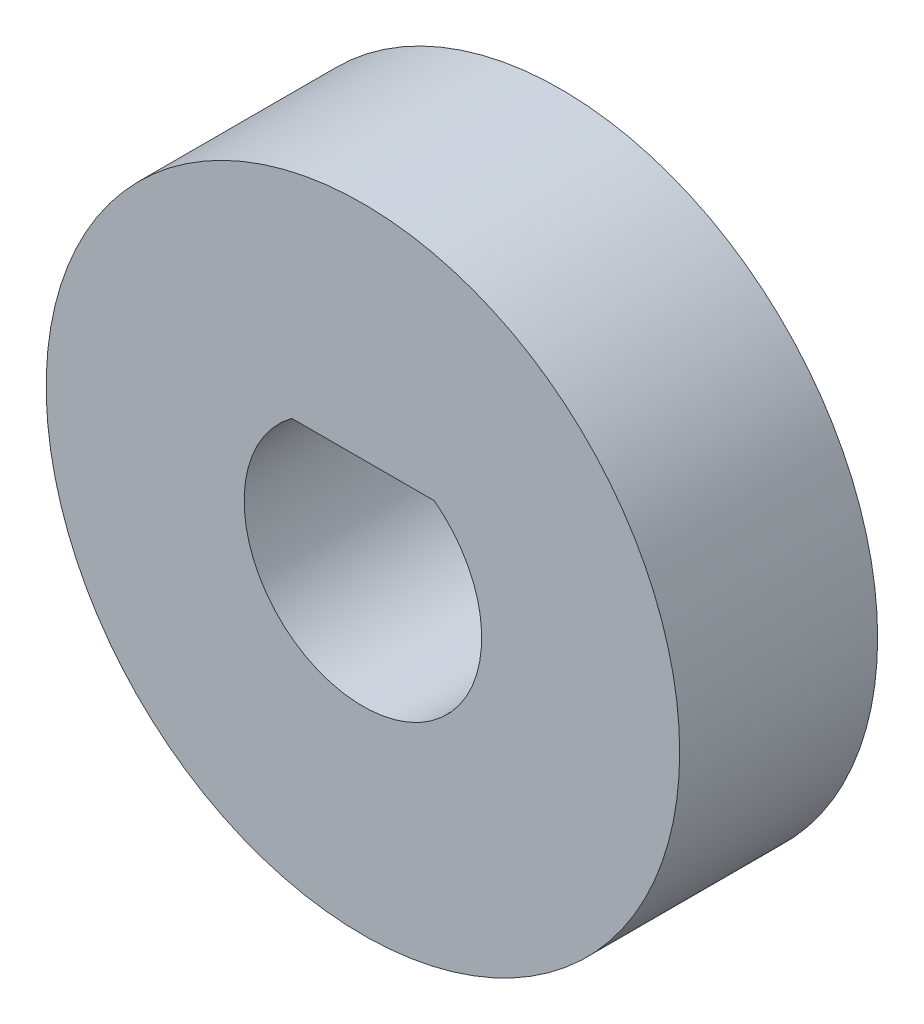
from build123d import *

# Parameters (mm, degrees)
ESQUISSE1_R        = 8
BOSS_EXTRU_1_DEPTH = 5


with BuildPart() as part:
    # Esquisse1 → Boss.-Extru.1 (new body)
    with BuildSketch(Plane.XY):
        Circle(ESQUISSE1_R)
        with BuildLine():
            Line((-1.8, 2.4), (1.8, 2.4))
            ThreePointArc((1.8, 2.4), (0, -3), (-1.8, 2.4))
        make_face(mode=Mode.SUBTRACT)
    extrude(amount=BOSS_EXTRU_1_DEPTH)


solid = part.part
